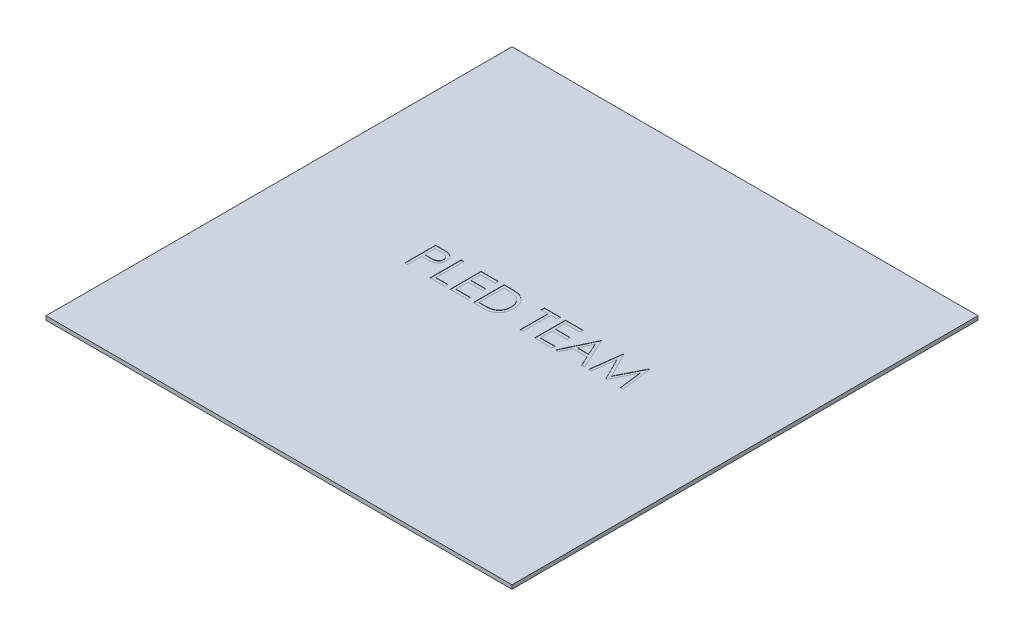
from build123d import *

# Parameters (mm, degrees)
SKETCH1_W           = 381
SKETCH1_H           = 381
BOSS_EXTRUDE1_DEPTH = 3.175
CUT_EXTRUDE1_DEPTH  = 0.254


with BuildPart() as part:
    # Sketch1 → Boss-Extrude1 (new body)
    with BuildSketch(Plane(origin=(0, 0, 0), x_dir=(1, 0, 0), z_dir=(0, 1, 0))):
        Rectangle(SKETCH1_W, SKETCH1_H)
    extrude(amount=BOSS_EXTRUDE1_DEPTH)

    # Sketch3 → Cut-Extrude1 (cut)
    with BuildSketch(Plane(origin=(0, 3.175, 0), x_dir=(1, 0, 0), z_dir=(0, 1, 0))):
        with BuildLine():
            Line((-81.199118404, 18.794440271), (-76.217828339, 18.794440271))
            add(Edge.make_bspline(
                [(-76.217828339, 18.794440271), (-75.875212049, 18.794063653), (-75.218744021, 18.793342035), (-74.277383331, 18.771463594), (-73.422421279, 18.742241314), (-72.655701372, 18.701732718), (-71.974864545, 18.65386032), (-71.382991572, 18.586716949), (-70.87543022, 18.516610804), (-70.57130913, 18.445335454), (-70.432611993, 18.412829694)],
                knots=[0, 0, 0, 0, 0.001027817, 0.001969343, 0.002824696, 0.003594083, 0.004272716, 0.004871692, 0.005381167, 0.005808328, 0.005808328, 0.005808328, 0.005808328], degree=3))
            add(Edge.make_bspline(
                [(-70.432611993, 18.412829694), (-70.257036062, 18.364773259), (-69.910021428, 18.269792777), (-69.409996715, 18.07955604), (-68.934263093, 17.853988327), (-68.481188355, 17.596911735), (-68.056340095, 17.297296498), (-67.653379683, 16.967287958), (-67.275863255, 16.59926686), (-66.925913725, 16.19736092), (-66.604532623, 15.768317111), (-66.327820068, 15.305730642), (-66.096119621, 14.81738804), (-65.897395308, 14.303628981), (-65.754368238, 13.760139205), (-65.646622166, 13.190695064), (-65.578233554, 12.595357598), (-65.571683534, 12.188523131), (-65.568349173, 11.981419438)],
                knots=[0, 0, 0, 0, 0.000545856, 0.001078849, 0.001602335, 0.00212426, 0.00263947, 0.003160005, 0.003685341, 0.004219039, 0.004757373, 0.005291409, 0.005833051, 0.006377364, 0.006941436, 0.007516239, 0.008115215, 0.008736301, 0.008736301, 0.008736301, 0.008736301], degree=3))
            add(Edge.make_bspline(
                [(-65.568349173, 11.981419438), (-65.571407512, 11.772575001), (-65.57739136, 11.363956754), (-65.649210116, 10.766165662), (-65.745949221, 10.19489506), (-65.894699258, 9.651411619), (-66.089522143, 9.138942885), (-66.318064469, 8.649657373), (-66.593716375, 8.191879182), (-66.91045314, 7.763946386), (-67.262798996, 7.365457308), (-67.649263176, 6.999299657), (-68.06828547, 6.667616744), (-68.518534202, 6.369664993), (-69.004398819, 6.112353707), (-69.518510448, 5.881886408), (-70.065337733, 5.688330711), (-70.443743405, 5.586512551), (-70.636137634, 5.534744759)],
                knots=[0, 0, 0, 0, 0.000626172, 0.001225148, 0.001804035, 0.002363198, 0.002912269, 0.00344713, 0.003981166, 0.004512384, 0.005042259, 0.005574937, 0.006107347, 0.006643609, 0.007192233, 0.007754835, 0.00833258, 0.008930149, 0.008930149, 0.008930149, 0.008930149], degree=3))
            add(Edge.make_bspline(
                [(-70.636137634, 5.534744759), (-70.79526743, 5.500904839), (-71.144009628, 5.426742687), (-71.718359669, 5.343949886), (-72.387071898, 5.273282727), (-73.149233587, 5.220297328), (-74.004160611, 5.174937511), (-74.95231545, 5.138883344), (-75.995559325, 5.119072405), (-76.723242067, 5.118050651), (-77.103164878, 5.117517194)],
                knots=[0, 0, 0, 0, 0.000487958, 0.001069388, 0.00173973, 0.002505, 0.003361034, 0.004308098, 0.005351366, 0.006491121, 0.006491121, 0.006491121, 0.006491121], degree=3))
            Line((-77.103164878, 5.117517194), (-78.919631224, 5.117517194))
            Line((-78.919631224, 5.117517194), (-78.919631224, -6.605559729))
            Line((-78.919631224, -6.605559729), (-81.199118404, -6.605559729))
            Line((-81.199118404, -6.605559729), (-81.199118404, 18.794440271))
        make_face()
        with BuildLine():
            Line((-78.919631224, 16.189312066), (-78.919631224, 7.7226454))
            Line((-78.919631224, 7.7226454), (-74.472595968, 7.666675848))
            add(Edge.make_bspline(
                [(-74.472595968, 7.666675848), (-74.255462792, 7.666563627), (-73.836291672, 7.666346986), (-73.230783081, 7.695268322), (-72.669012824, 7.728655044), (-72.152706477, 7.777538603), (-71.681631296, 7.846635729), (-71.2550018, 7.916389484), (-70.87612609, 8.017302687), (-70.432720455, 8.153178675), (-69.938629876, 8.384918228), (-69.401111095, 8.721286002), (-68.945575983, 9.150043141), (-68.551380343, 9.632119403), (-68.238554829, 10.168415942), (-68.009548485, 10.742230511), (-67.874992657, 11.347678334), (-67.856949995, 11.761975113), (-67.847836352, 11.971243156)],
                knots=[0, 0, 0, 0, 0.000651302, 0.001257325, 0.001818153, 0.002339631, 0.00281239, 0.003246555, 0.003635291, 0.003987697, 0.00463661, 0.005266081, 0.00588183, 0.006504041, 0.007128868, 0.007736406, 0.008351208, 0.008978723, 0.008978723, 0.008978723, 0.008978723], degree=3))
            add(Edge.make_bspline(
                [(-67.847836352, 11.971243156), (-67.856999558, 12.175448368), (-67.875214878, 12.581383056), (-68.010603142, 13.176314633), (-68.238109591, 13.744082316), (-68.553480305, 14.273658421), (-68.93623022, 14.754000027), (-69.38108831, 15.171264892), (-69.887007407, 15.506702392), (-70.357620283, 15.723206778), (-70.775640319, 15.855397634), (-71.138729399, 15.947888762), (-71.548690294, 16.021734591), (-72.005656465, 16.081529839), (-72.50608606, 16.132717815), (-73.054278402, 16.167450336), (-73.648156842, 16.187780904), (-74.06043927, 16.188789322), (-74.274158468, 16.189312066)],
                knots=[0, 0, 0, 0, 0.000612292, 0.00121716, 0.001819971, 0.002440411, 0.003059431, 0.003657066, 0.004262469, 0.004872643, 0.005204115, 0.005576802, 0.005995948, 0.006452891, 0.00695918, 0.007504775, 0.008100435, 0.008741561, 0.008741561, 0.008741561, 0.008741561], degree=3))
            Line((-74.274158468, 16.189312066), (-78.919631224, 16.189312066))
        make_face(mode=Mode.SUBTRACT)
        Polygon((-60.358092763, 18.794440271), (-58.078605583, 18.794440271), (-58.078605583, -4.000431523), (-48.309374814, -4.000431523), (-48.309374814, -6.605559729), (-60.358092763, -6.605559729), align=None)
        Polygon((-44.07604148, 18.794440271), (-29.747836352, 18.794440271), (-29.747836352, 16.189312066), (-41.796554301, 16.189312066), (-41.796554301, 8.373927451), (-29.747836352, 8.373927451), (-29.747836352, 5.768799246), (-41.796554301, 5.768799246), (-41.796554301, -4.000431523), (-29.747836352, -4.000431523), (-29.747836352, -6.605559729), (-44.07604148, -6.605559729), align=None)
        with BuildLine():
            Line((-25.188861993, -6.605559729), (-25.188861993, 18.794440271))
            Line((-25.188861993, 18.794440271), (-20.060015839, 18.794440271))
            add(Edge.make_bspline(
                [(-20.060015839, 18.794440271), (-19.613926611, 18.791228478), (-18.752084542, 18.785023309), (-17.506668495, 18.745679499), (-16.354352048, 18.676080118), (-15.298925013, 18.574701272), (-14.337489932, 18.450219256), (-13.47273889, 18.29418775), (-12.700200482, 18.109942171), (-12.225079399, 17.952858046), (-12.000400455, 17.878574887)],
                knots=[0, 0, 0, 0, 0.001338268, 0.002585527, 0.003737651, 0.004800866, 0.005765857, 0.006645105, 0.007436143, 0.008145806, 0.008145806, 0.008145806, 0.008145806], degree=3))
            add(Edge.make_bspline(
                [(-12.000400455, 17.878574887), (-11.706524347, 17.766592052), (-11.125436266, 17.54516578), (-10.29807029, 17.127471479), (-9.519194799, 16.654210684), (-8.784633005, 16.124759566), (-8.11116415, 15.524126865), (-7.472478271, 14.877826873), (-6.894702847, 14.162357204), (-6.365596927, 13.392555862), (-5.888543856, 12.577491255), (-5.473876825, 11.718716466), (-5.129496416, 10.820592727), (-4.843614143, 9.885617653), (-4.618305565, 8.911735369), (-4.464585261, 7.897811884), (-4.363195791, 6.847854338), (-4.353006391, 6.135388229), (-4.347836352, 5.773887387)],
                knots=[0, 0, 0, 0, 0.000942955, 0.001864527, 0.002775545, 0.003675226, 0.004576531, 0.005479658, 0.00639829, 0.007331197, 0.008279791, 0.009228767, 0.010188795, 0.011162546, 0.012159835, 0.013184587, 0.014237193, 0.015321397, 0.015321397, 0.015321397, 0.015321397], degree=3))
            add(Edge.make_bspline(
                [(-4.347836352, 5.773887387), (-4.352400859, 5.459934399), (-4.361395697, 4.841257245), (-4.442162732, 3.929463317), (-4.559556597, 3.044719113), (-4.741305919, 2.191237747), (-4.961941302, 1.361541537), (-5.244709714, 0.56447325), (-5.568635886, -0.207278966), (-5.946369291, -0.943280077), (-6.361052485, -1.640570837), (-6.806073136, -2.297890383), (-7.280956582, -2.905859136), (-7.790231175, -3.466318206), (-8.327315746, -3.978422689), (-8.895726602, -4.446450458), (-9.496930456, -4.861243742), (-10.128234559, -5.239102184), (-10.808055611, -5.568724193), (-11.549270182, -5.847616264), (-12.355039303, -6.078731701), (-13.223385161, -6.271560488), (-14.155808114, -6.424521484), (-15.153222323, -6.527038732), (-16.21409534, -6.596365729), (-16.942562008, -6.602435556), (-17.317507827, -6.605559729)],
                knots=[0, 0, 0, 0, 0.00094165, 0.001855619, 0.002744298, 0.003617459, 0.0044716, 0.005318038, 0.006152509, 0.006980814, 0.007797583, 0.008585062, 0.009360666, 0.010109885, 0.010854859, 0.01158518, 0.012316316, 0.01304408, 0.013790495, 0.014579567, 0.015416872, 0.016303202, 0.017246761, 0.018249744, 0.019310143, 0.020434806, 0.020434806, 0.020434806, 0.020434806], degree=3))
            Line((-17.317507827, -6.605559729), (-25.188861993, -6.605559729))
        make_face()
        with BuildLine():
            Line((-22.909374814, -4.000431523), (-19.993870006, -4.000431523))
            add(Edge.make_bspline(
                [(-19.993870006, -4.000431523), (-19.574926973, -3.998631053), (-18.769146093, -3.995168088), (-17.610485198, -3.964780957), (-16.551817578, -3.915128039), (-15.59299291, -3.845640331), (-14.734552562, -3.753702381), (-13.974702492, -3.651195944), (-13.315933474, -3.52348873), (-12.917302703, -3.407730339), (-12.733092763, -3.354237613)],
                knots=[0, 0, 0, 0, 0.001256812, 0.00241731, 0.003476866, 0.004436085, 0.005300844, 0.00606647, 0.006736039, 0.007311269, 0.007311269, 0.007311269, 0.007311269], degree=3))
            add(Edge.make_bspline(
                [(-12.733092763, -3.354237613), (-12.501238935, -3.272583448), (-12.043069103, -3.111225425), (-11.383532085, -2.816892683), (-10.768438394, -2.46824452), (-10.187068496, -2.080696589), (-9.64766934, -1.640579889), (-9.14384861, -1.157464713), (-8.67662068, -0.628892345), (-8.250812845, -0.05551883), (-7.869752582, 0.559087116), (-7.539761374, 1.208883223), (-7.250553116, 1.886749789), (-7.023559901, 2.603096254), (-6.845646804, 3.351518564), (-6.719628783, 4.132069369), (-6.641144783, 4.9446029), (-6.631990275, 5.497249745), (-6.627323532, 5.778975528)],
                knots=[0, 0, 0, 0, 0.000737271, 0.001456933, 0.002163159, 0.002856062, 0.003550589, 0.004248722, 0.004948041, 0.005664457, 0.006388798, 0.007114711, 0.007848974, 0.008597207, 0.009366072, 0.010154882, 0.010967488, 0.011812503, 0.011812503, 0.011812503, 0.011812503], degree=3))
            add(Edge.make_bspline(
                [(-6.627323532, 5.778975528), (-6.631048531, 6.076035642), (-6.638366326, 6.659612866), (-6.730345608, 7.515888197), (-6.864759182, 8.339433489), (-7.059132218, 9.130303822), (-7.306824881, 9.890042149), (-7.615940282, 10.614446594), (-7.96912089, 11.311167643), (-8.389333677, 11.964124468), (-8.849549698, 12.581657318), (-9.360292022, 13.147387276), (-9.913446245, 13.662603055), (-10.502979152, 14.135328353), (-11.145505529, 14.546544744), (-11.825889457, 14.914385229), (-12.554112328, 15.226557698), (-13.060753035, 15.392592873), (-13.31822898, 15.476972323)],
                knots=[0, 0, 0, 0, 0.000890788, 0.001749961, 0.002580591, 0.003392608, 0.004190684, 0.004975051, 0.00575332, 0.006531074, 0.007301419, 0.008061598, 0.008813972, 0.009567292, 0.010325169, 0.011099169, 0.011885529, 0.01269812, 0.01269812, 0.01269812, 0.01269812], degree=3))
            add(Edge.make_bspline(
                [(-13.31822898, 15.476972323), (-13.531234443, 15.535874399), (-13.984142498, 15.661116375), (-14.723206037, 15.797734793), (-15.55498455, 15.918236014), (-16.483170952, 16.020257214), (-17.506707198, 16.093462346), (-18.626380477, 16.148408458), (-19.84267475, 16.185468019), (-20.685827996, 16.187998637), (-21.123437314, 16.189312066)],
                knots=[0, 0, 0, 0, 0.000662729, 0.001409144, 0.002252487, 0.003184103, 0.004209664, 0.005330453, 0.00654704, 0.00785982, 0.00785982, 0.00785982, 0.00785982], degree=3))
            Line((-21.123437314, 16.189312066), (-22.909374814, 16.189312066))
            Line((-22.909374814, 16.189312066), (-22.909374814, -4.000431523))
        make_face(mode=Mode.SUBTRACT)
        Polygon((7.700881596, 16.189312066), (7.700881596, 18.794440271), (21.052163648, 18.794440271), (21.052163648, 16.189312066), (15.516266212, 16.189312066), (15.516266212, -6.605559729), (13.236779032, -6.605559729), (13.236779032, 16.189312066), align=None)
        Polygon((24.959855955, 18.794440271), (39.288061084, 18.794440271), (39.288061084, 16.189312066), (27.239343135, 16.189312066), (27.239343135, 8.373927451), (39.288061084, 8.373927451), (39.288061084, 5.768799246), (27.239343135, 5.768799246), (27.239343135, -4.000431523), (39.288061084, -4.000431523), (39.288061084, -6.605559729), (24.959855955, -6.605559729), align=None)
        Polygon((54.267548263, 18.794440271), (65.990625186, -6.605559729), (63.512700507, -6.605559729), (59.75765243, 1.535465912), (48.243189289, 1.535465912), (44.38129025, -6.605559729), (41.893189289, -6.605559729), (53.941907237, 18.794440271), align=None)
        Polygon((54.079287045, 13.843679053), (49.479607558, 4.140594118), (58.556851148, 4.140594118), align=None, mode=Mode.SUBTRACT)
        Polygon((69.247035443, -6.605559729), (72.600120378, 18.794440271), (72.925761404, 18.794440271), (83.412420058, -2.04658537), (93.873638007, 18.794440271), (94.204367173, 18.794440271), (97.577804673, -6.605559729), (95.288141212, -6.605559729), (92.856009802, 11.671042836), (83.687179673, -6.605559729), (83.17327743, -6.605559729), (73.968830314, 11.711747964), (71.541787045, -6.605559729), align=None)
    extrude(amount=-CUT_EXTRUDE1_DEPTH, mode=Mode.SUBTRACT)


solid = part.part
